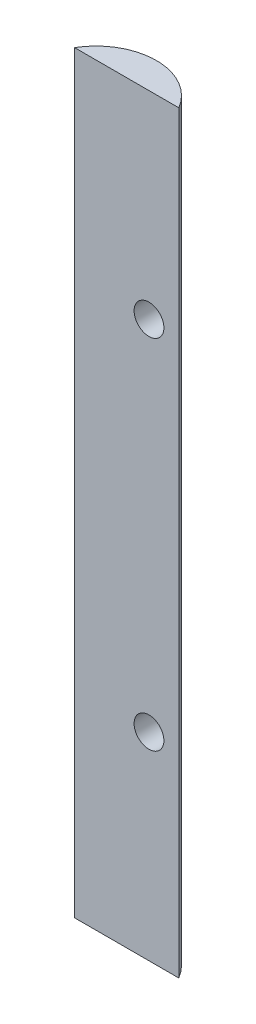
from build123d import *

# Parameters (mm, degrees)
BOSS_EXTRUDE1_START     = -6.35
BOSS_EXTRUDE1_DEPTH     = 160.651952
SKETCH1_R               = 3.175
CUT_EXTRUDE2_DEPTH      = 1
CUT_EXTRUDE2_DEPTH_BACK = 7.35


with BuildPart() as part:
    # Sketch2 → Boss-Extrude1 (new body)
    with BuildSketch(Plane(origin=(0, 0, 0), x_dir=(1, 0, 0), z_dir=(0, 1, 0)).offset(BOSS_EXTRUDE1_START)):
        with BuildLine():
            Line((0, 0), (6.35, 0))
            ThreePointArc((6.35, 0), (-4.7625, 6.35), (-15.875, 0))
            Line((-15.875, 0), (0, 0))
        make_face()
    extrude(amount=BOSS_EXTRUDE1_DEPTH)

    # Sketch1 → Cut-Extrude2 (cut, two sides)
    with BuildSketch(Plane.XY) as cut_extrude2_sk:
        with Locations((0, 35.875976)):
            Circle(SKETCH1_R)
        with Locations((0, 112.075976)):
            Circle(SKETCH1_R)
    extrude(amount=CUT_EXTRUDE2_DEPTH, mode=Mode.SUBTRACT)
    extrude(cut_extrude2_sk.sketch, amount=-CUT_EXTRUDE2_DEPTH_BACK, mode=Mode.SUBTRACT)


solid = part.part
